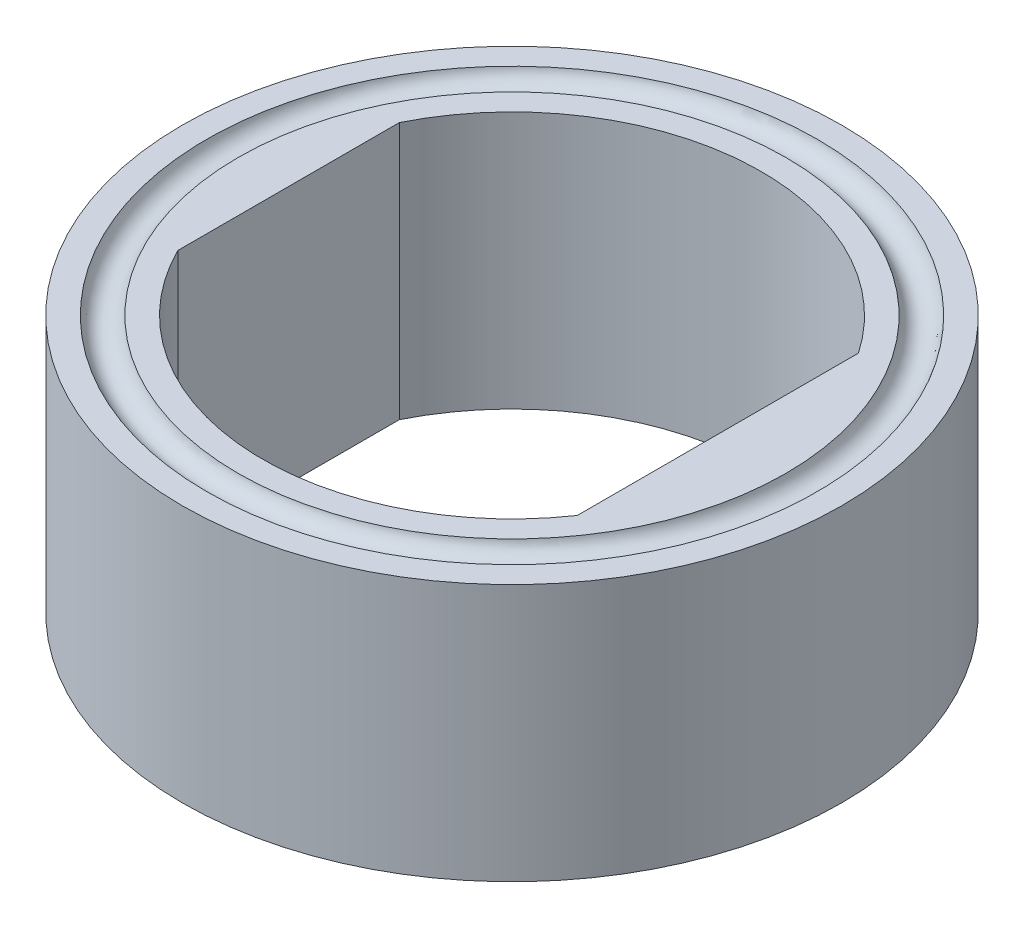
from build123d import *

# Parameters (mm, degrees)
SKETCH1_R           = 65.0875
SKETCH1_R_2         = 49.2125
BOSS_EXTRUDE1_DEPTH = 25.4
SKETCH11_R          = 3.175
BOSS_EXTRUDE2_DEPTH = 50.8
BOSS_EXTRUDE4_DEPTH = 50.8


with BuildPart() as part:
    # Sketch1 → Boss-Extrude1 (new body, symmetric)
    with BuildSketch(Plane(origin=(0, 0, 0), x_dir=(1, 0, 0), z_dir=(0, 1, 0))):
        Circle(SKETCH1_R)
        Circle(SKETCH1_R_2, mode=Mode.SUBTRACT)
    extrude(amount=BOSS_EXTRUDE1_DEPTH, both=True)

    # Sketch11 → Cut-Revolve1 (revolve, cut)
    with BuildSketch(Plane.XY):
        with Locations((57.15, 26.035)):
            Circle(SKETCH11_R)
    cut_revolve1 = revolve(axis=Axis((0, 0, 0), (0, 1, 0)), mode=Mode.SUBTRACT)

    # Mirror1: Cut-Revolve1 across plane
    add(cut_revolve1.mirror(Plane.ZX), mode=Mode.SUBTRACT)

    # Sketch3 → Boss-Extrude2 (add, through all)
    with BuildSketch(Plane(origin=(0, 25.4, 0), x_dir=(1, 0, 0), z_dir=(0, 1, 0))):
        with BuildLine():
            Line((-44.0944, -21.853009973), (-44.0944, 21.853009973))
            ThreePointArc((-44.0944, 21.853009973), (-49.2125, 0), (-44.0944, -21.853009973))
        make_face()
    extrude(amount=-BOSS_EXTRUDE2_DEPTH)

    # Sketch6 → Boss-Extrude4 (add, through all)
    with BuildSketch(Plane(origin=(0, 25.4, 0), x_dir=(1, 0, 0), z_dir=(0, 1, 0))):
        with BuildLine():
            Line((40.64, 27.753568352), (40.64, -27.753568352))
            ThreePointArc((40.64, -27.753568352), (49.2125, 0), (40.64, 27.753568352))
        make_face()
    extrude(amount=-BOSS_EXTRUDE4_DEPTH)


solid = part.part
